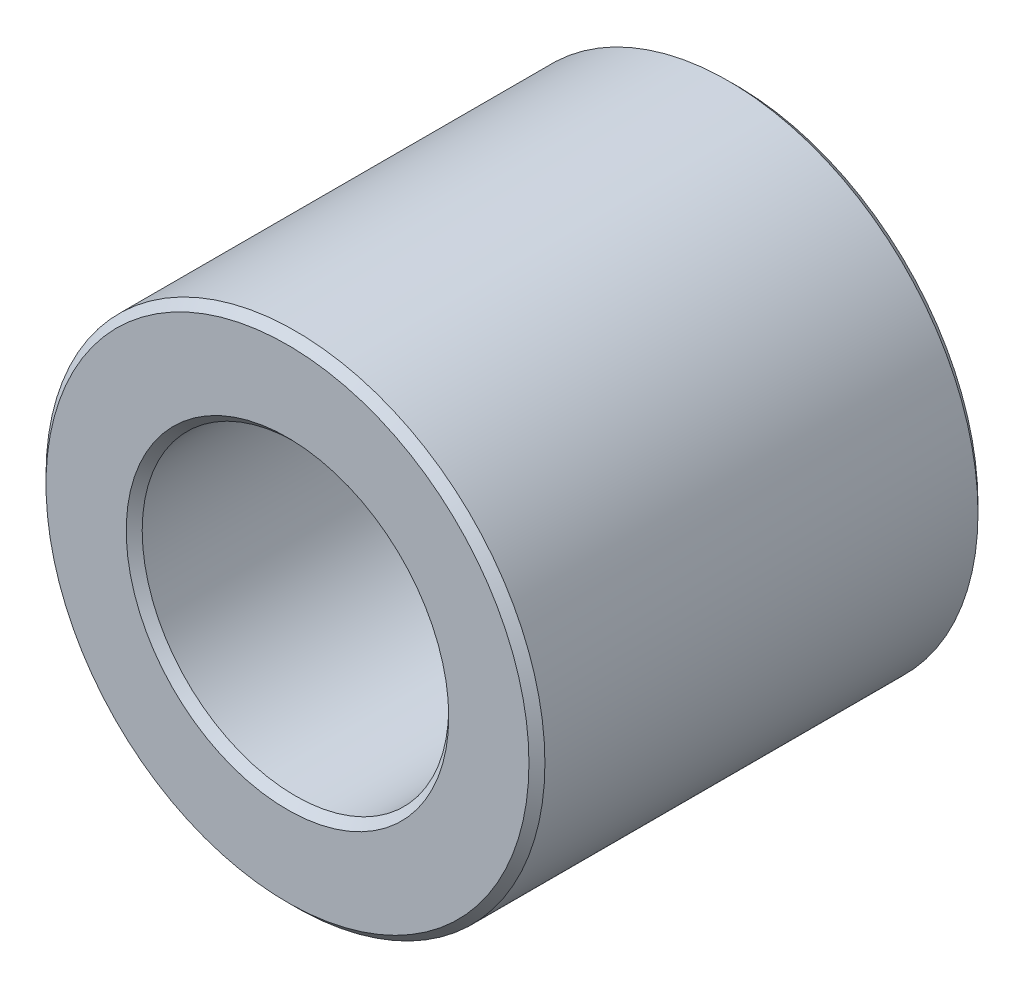
from build123d import *

# Parameters (mm, degrees)
SKETCH3_R                = 3.96875
SKETCH3_R_2              = 2.4384
BOSS_EXTRUDE1_DEPTH      = 3.571875
BOSS_EXTRUDE1_DEPTH_BACK = 3.571875
CHAMFER1_SIZE            = 0.127


with BuildPart() as part:
    # Sketch3 → Boss-Extrude1 (new body, two sides)
    with BuildSketch(Plane.XY) as boss_extrude1_sk:
        Circle(SKETCH3_R)
        Circle(SKETCH3_R_2, mode=Mode.SUBTRACT)
    extrude(amount=BOSS_EXTRUDE1_DEPTH)
    extrude(boss_extrude1_sk.sketch, amount=-BOSS_EXTRUDE1_DEPTH_BACK)

    # Chamfer1
    chamfer1_edges = [part.edges().sort_by_distance(p)[0] for p in [
        (-3.96875, 0, -3.571875),
        (-2.4384, 0, -3.571875),
        (-3.96875, 0, 3.571875),
        (-2.4384, 0, 3.571875),
    ]]
    chamfer(chamfer1_edges, length=CHAMFER1_SIZE)


solid = part.part
